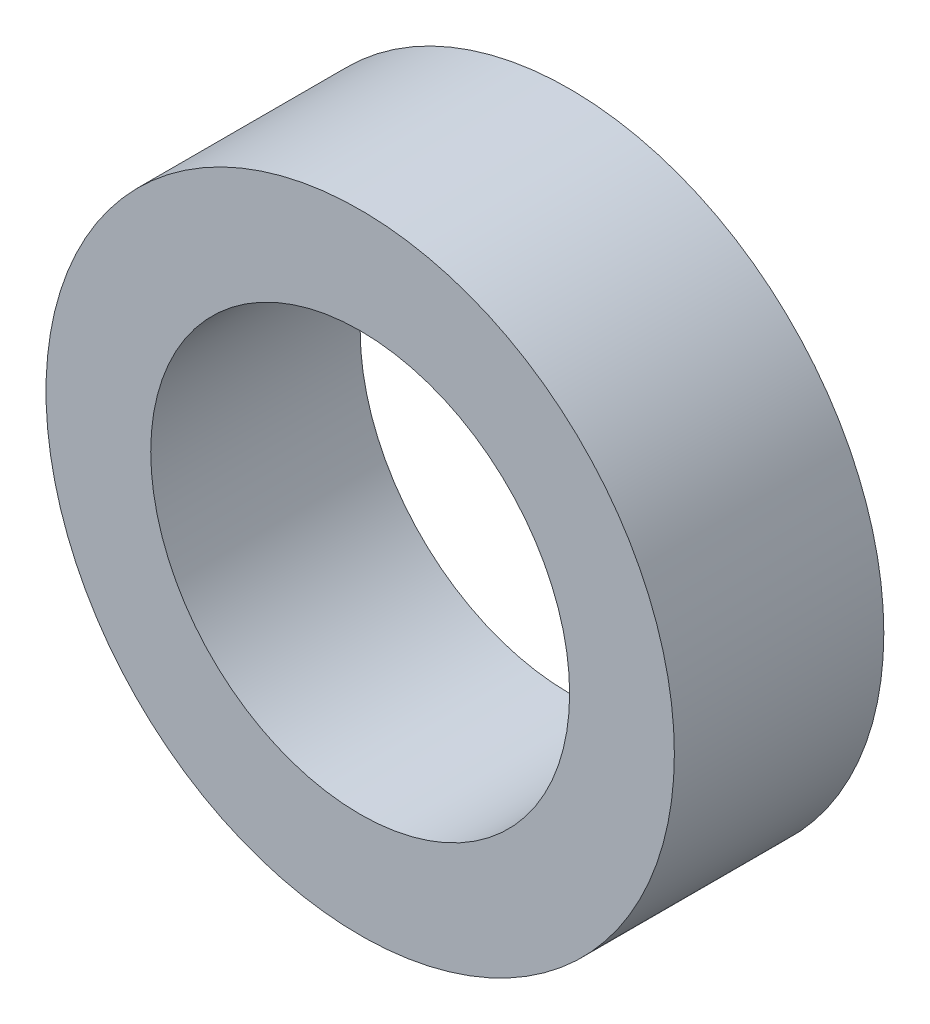
from build123d import *

# Parameters (mm, degrees)
SKETCH_1_R      = 7.5
SKETCH_1_R_2    = 5
EXTRUDE_1_DEPTH = 5


with BuildPart() as part:
    # 草图1 → 凸台-拉伸1 (new body)
    with BuildSketch(Plane.XY):
        Circle(SKETCH_1_R)
        Circle(SKETCH_1_R_2, mode=Mode.SUBTRACT)
    extrude(amount=EXTRUDE_1_DEPTH)


solid = part.part
